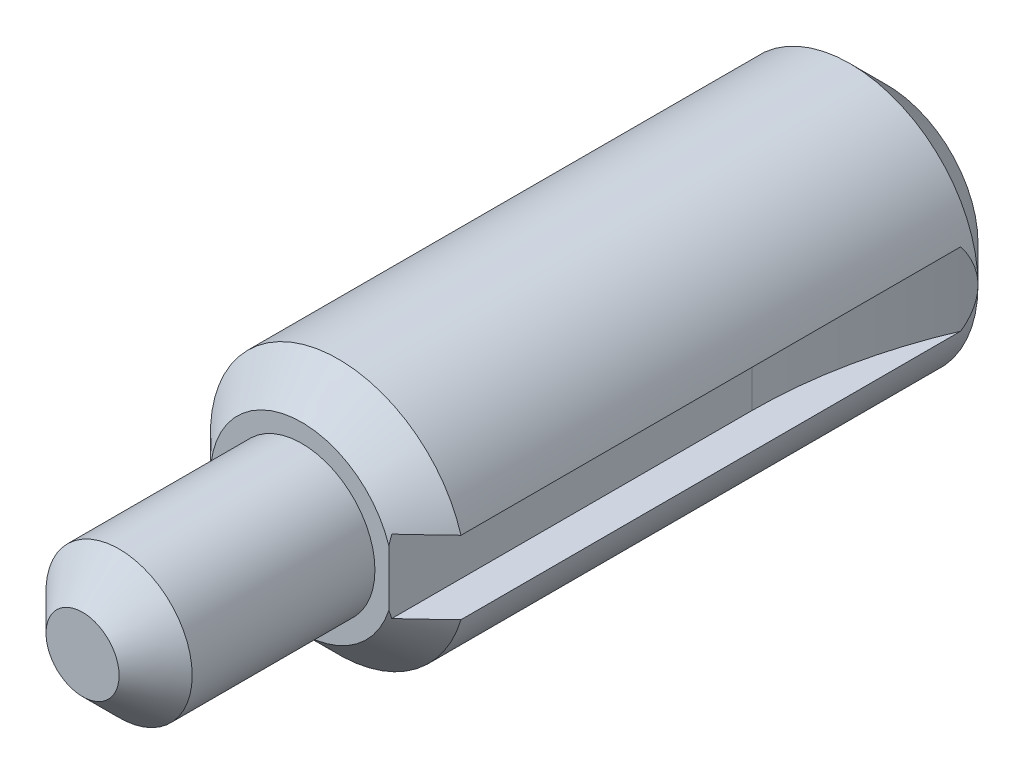
from build123d import *

# Parameters (mm, degrees)
SKETCH1_R          = 5.55625
EXTRUDE1_DEPTH     = 25.4
SKETCH2_R          = 3.175
EXTRUDE2_DEPTH     = 9.525
CHAMFER1_SIZE      = 1.5875
CUT_EXTRUDE1_DEPTH = 1.5875


with BuildPart() as part:
    # Sketch1 → Extrude1 (new body)
    with BuildSketch(Plane.XY):
        Circle(SKETCH1_R)
    extrude(amount=EXTRUDE1_DEPTH)

    # Sketch2 → Extrude2 (add)
    with BuildSketch(Plane.XY.offset(25.4)):
        Circle(SKETCH2_R)
    extrude(amount=EXTRUDE2_DEPTH)

    # Chamfer1
    chamfer1_edges = [part.edges().sort_by_distance(p)[0] for p in [
        (-5.55625, 0, 0),
        (-5.55625, 0, 25.4),
        (-3.175, 0, 34.925),
    ]]
    chamfer(chamfer1_edges, length=CHAMFER1_SIZE)

    # Sketch3 → Cut-Extrude1 (cut, symmetric)
    with BuildSketch(Plane(origin=(0, 0, 0), x_dir=(1, 0, 0), z_dir=(0, 1, 0))):
        with BuildLine():
            Line((3.77825, -9.623700346), (3.77825, -25.4))
            Line((3.77825, -25.4), (5.55625, -25.4))
            Line((5.55625, -25.4), (5.55625, -1.5875))
            ThreePointArc((5.55625, -1.5875), (4.228060485, -5.508430002), (3.77825, -9.623700346))
        make_face()
    extrude(amount=CUT_EXTRUDE1_DEPTH, both=True, mode=Mode.SUBTRACT)


solid = part.part
